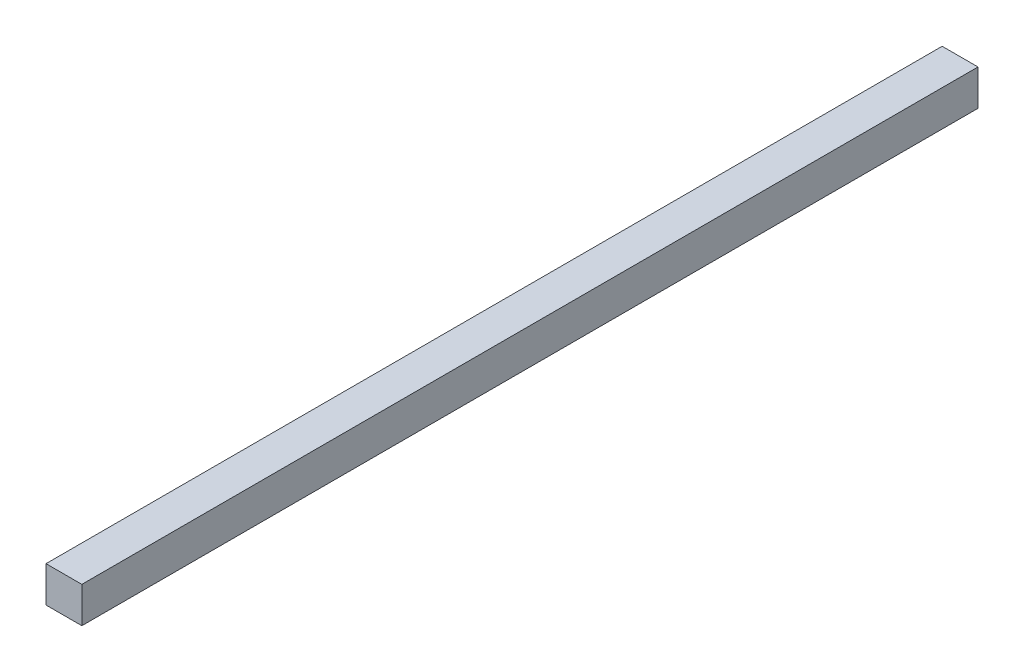
from build123d import *

# Parameters (mm, degrees)
SKETCH_1_W      = 20
SKETCH_1_H      = 20
EXTRUDE_1_DEPTH = 500


with BuildPart() as part:
    # 草图1 → 凸台-拉伸1 (new body)
    with BuildSketch(Plane.XY):
        Rectangle(SKETCH_1_W, SKETCH_1_H)
    extrude(amount=EXTRUDE_1_DEPTH)


solid = part.part
